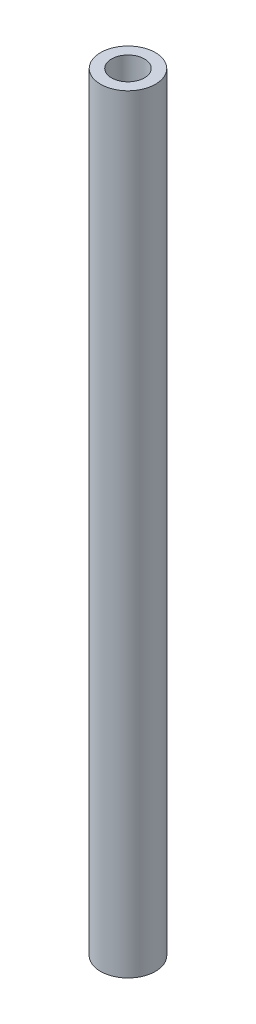
from build123d import *

# Parameters (mm, degrees)
SKETCH_1_R      = 2.5
SKETCH_1_R_2    = 1.5
EXTRUDE_1_DEPTH = 70


with BuildPart() as part:
    # 草图1 → 凸台-拉伸1 (new body)
    with BuildSketch(Plane(origin=(0, 0, 0), x_dir=(1, 0, 0), z_dir=(0, 1, 0))):
        Circle(SKETCH_1_R)
        Circle(SKETCH_1_R_2, mode=Mode.SUBTRACT)
    extrude(amount=EXTRUDE_1_DEPTH)


solid = part.part
